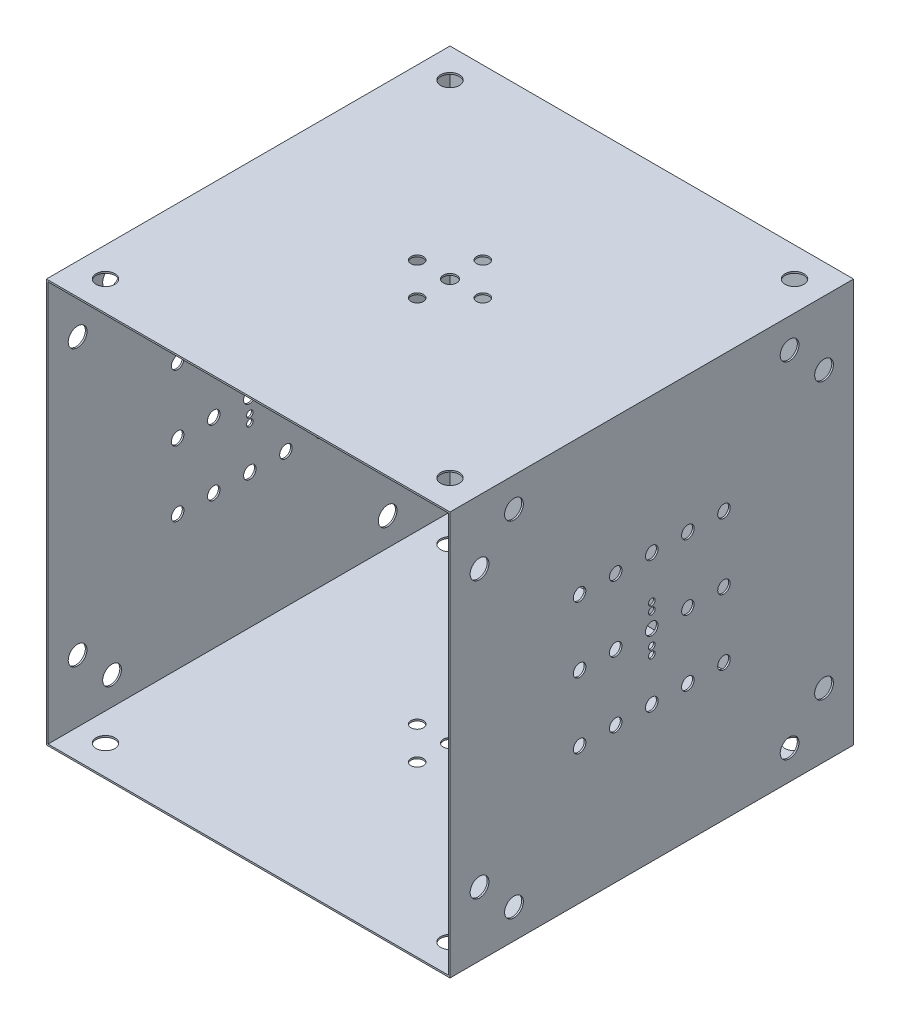
from build123d import *

# Parameters (mm, degrees)
SKETCH1_W           = 2460
SKETCH1_H           = 2460
BOSS_EXTRUDE1_DEPTH = 2460
SHELL1_T            = -10
SKETCH2_R           = 38.1
SKETCH2_R_2         = 20
SKETCH2_R_3         = 57.15
CUT_EXTRUDE1_DEPTH  = 2461
SKETCH3_R           = 41.2
SKETCH3_R_2         = 38.1
SKETCH3_R_3         = 57.15
CUT_EXTRUDE2_DEPTH  = 2461
SKETCH4_R           = 82.55
SKETCH4_R_2         = 57.15
SKETCH4_R_3         = 25
CUT_EXTRUDE3_DEPTH  = 2461


with BuildPart() as part:
    # Sketch1 → Boss-Extrude1 (new body)
    with BuildSketch(Plane.XY):
        Rectangle(SKETCH1_W, SKETCH1_H)
    extrude(amount=BOSS_EXTRUDE1_DEPTH)

    # Shell1
    shell1_openings = [part.faces().sort_by_distance(p)[0] for p in [
        (0, 0, 2460),
    ]]
    offset(amount=SHELL1_T, openings=shell1_openings, kind=Kind.INTERSECTION)

    # Sketch2 → Cut-Extrude1 (cut, through all)
    with BuildSketch(Plane.ZY.offset(1230)):
        with Locations((1230, 0)):
            Circle(SKETCH2_R)
        with Locations((1010, 0)):
            Circle(SKETCH2_R)
        with Locations((790, 0)):
            Circle(SKETCH2_R)
        with Locations((1450, 0)):
            Circle(SKETCH2_R)
        with Locations((1670, 0)):
            Circle(SKETCH2_R)
        with Locations((790, 400)):
            Circle(SKETCH2_R)
        with Locations((1010, 400)):
            Circle(SKETCH2_R)
        with Locations((1230, 400)):
            Circle(SKETCH2_R)
        with Locations((1450, 400)):
            Circle(SKETCH2_R)
        with Locations((1670, 400)):
            Circle(SKETCH2_R)
        with Locations((1670, -400)):
            Circle(SKETCH2_R)
        with Locations((1450, -400)):
            Circle(SKETCH2_R)
        with Locations((1230, -400)):
            Circle(SKETCH2_R)
        with Locations((1010, -400)):
            Circle(SKETCH2_R)
        with Locations((790, -400)):
            Circle(SKETCH2_R)
        with Locations((1230, 92.5)):
            Circle(SKETCH2_R_2)
        with Locations((1230, 140)):
            Circle(SKETCH2_R_2)
        with Locations((1230, -140)):
            Circle(SKETCH2_R_2)
        with Locations((1230, -92.5)):
            Circle(SKETCH2_R_2)
        with Locations((390, 1050)):
            Circle(SKETCH2_R_3)
        with Locations((180, 840)):
            Circle(SKETCH2_R_3)
        with Locations((2280, 840)):
            Circle(SKETCH2_R_3)
        with Locations((2070, 1050)):
            Circle(SKETCH2_R_3)
        with Locations((2280, -840)):
            Circle(SKETCH2_R_3)
        with Locations((2070, -1050)):
            Circle(SKETCH2_R_3)
        with Locations((180, -840)):
            Circle(SKETCH2_R_3)
        with Locations((390, -1050)):
            Circle(SKETCH2_R_3)
    extrude(amount=-CUT_EXTRUDE1_DEPTH, mode=Mode.SUBTRACT)

    # Sketch3 → Cut-Extrude2 (cut, through all)
    with BuildSketch(Plane(origin=(0, 1230, 0), x_dir=(1, 0, 0), z_dir=(0, 1, 0))):
        with Locations((0, -1230)):
            Circle(SKETCH3_R)
        with Locations((-200, -1230)):
            Circle(SKETCH3_R_2)
        with Locations((200, -1230)):
            Circle(SKETCH3_R_2)
        with Locations((0, -1430)):
            Circle(SKETCH3_R_2)
        with Locations((0, -1030)):
            Circle(SKETCH3_R_2)
        with Locations((-1050, -180)):
            Circle(SKETCH3_R_3)
        with Locations((1050, -180)):
            Circle(SKETCH3_R_3)
        with Locations((1050, -2280)):
            Circle(SKETCH3_R_3)
        with Locations((-1050, -2280)):
            Circle(SKETCH3_R_3)
    extrude(amount=-CUT_EXTRUDE2_DEPTH, mode=Mode.SUBTRACT)

    # Sketch4 → Cut-Extrude3 (cut, through all)
    with BuildSketch(Plane(origin=(0, 0, 0), x_dir=(-1, 0, 0), z_dir=(0, 0, -1))):
        Circle(SKETCH4_R)
        with Locations((-222, 382)):
            Circle(SKETCH4_R)
        with Locations((222, -382)):
            Circle(SKETCH4_R)
        with Locations((-900, 900)):
            Circle(SKETCH4_R_2)
        with Locations((900, 900)):
            Circle(SKETCH4_R_2)
        with Locations((900, -900)):
            Circle(SKETCH4_R_2)
        with Locations((-900, -900)):
            Circle(SKETCH4_R_2)
        with Locations((0, 140)):
            Circle(SKETCH4_R_3)
        with Locations((0, -140)):
            Circle(SKETCH4_R_3)
    extrude(amount=-CUT_EXTRUDE3_DEPTH, mode=Mode.SUBTRACT)


solid = part.part
